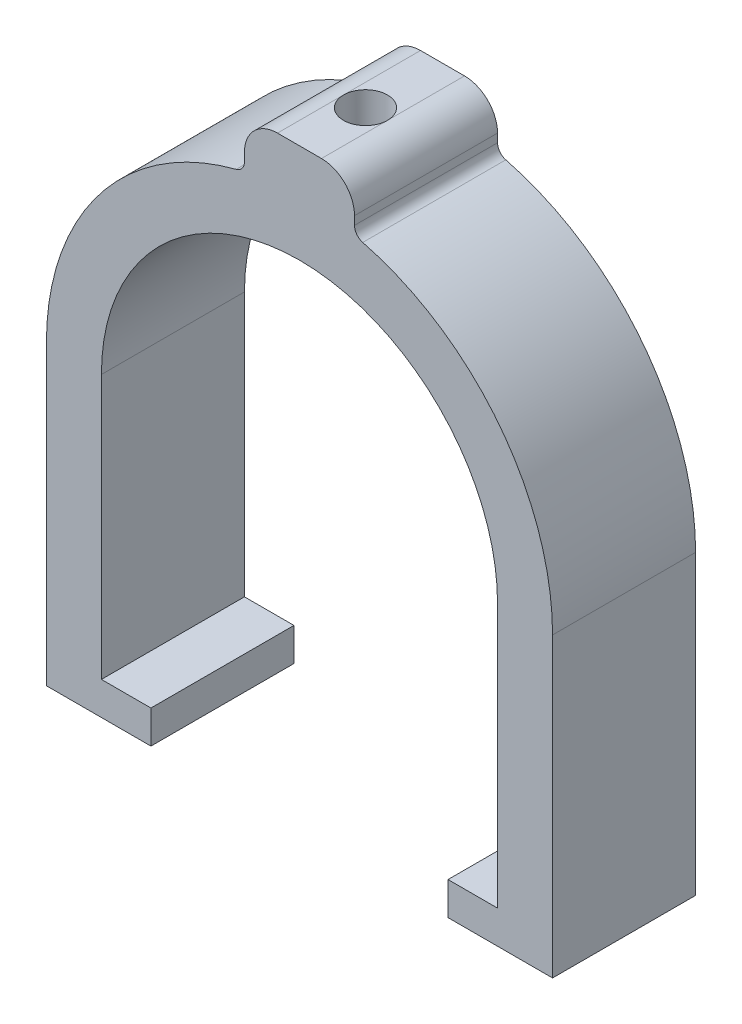
from build123d import *

# Parameters (mm, degrees)
BOSS_EXTRUDE2_DEPTH = 6.5
CUT_EXTRUDE1_START  = 44.888544
SKETCH3_R           = 2
CUT_EXTRUDE1_DEPTH  = 9.111456


with BuildPart() as part:
    # Sketch1 → Boss-Extrude2 (new body, symmetric)
    with BuildSketch(Plane.XY):
        with BuildLine():
            Line((-13.5, 0), (-23, 0))
            Line((-23, 0), (-23, 27))
            ThreePointArc((-23, 27), (-18.183096546, 41.084566021), (-5.75, 49.269654241))
            ThreePointArc((-5.75, 49.269654241), (-5.209430585, 49.625527642), (-5, 50.237900077))
            Line((-5, 50.237900077), (-5, 51))
            ThreePointArc((-5, 51), (-4.121320344, 53.121320344), (-2, 54))
            Line((-2, 54), (2, 54))
            ThreePointArc((2, 54), (4.121320344, 53.121320344), (5, 51))
            Line((5, 51), (5, 50.237900077))
            ThreePointArc((5, 50.237900077), (5.209430585, 49.625527642), (5.75, 49.269654241))
            ThreePointArc((5.75, 49.269654241), (18.183096546, 41.084566021), (23, 27))
            Line((23, 27), (23, 0))
            Line((23, 0), (13.5, 0))
            Line((13.5, 0), (13.5, 3))
            Line((13.5, 3), (18, 3))
            Line((18, 3), (18, 27))
            ThreePointArc((18, 27), (12.727922061, 39.727922061), (0, 45))
            ThreePointArc((0, 45), (-12.727922061, 39.727922061), (-18, 27))
            Line((-18, 27), (-18, 3))
            Line((-18, 3), (-13.5, 3))
            Line((-13.5, 3), (-13.5, 0))
        make_face()
    extrude(amount=BOSS_EXTRUDE2_DEPTH, both=True)

    # Sketch3 → Cut-Extrude1 (cut)
    with BuildSketch(Plane(origin=(0, 0, 0), x_dir=(1, 0, 0), z_dir=(0, 1, 0)).offset(CUT_EXTRUDE1_START)):
        with Locations((0, -0.5)):
            Circle(SKETCH3_R)
    extrude(amount=CUT_EXTRUDE1_DEPTH, mode=Mode.SUBTRACT)


solid = part.part
